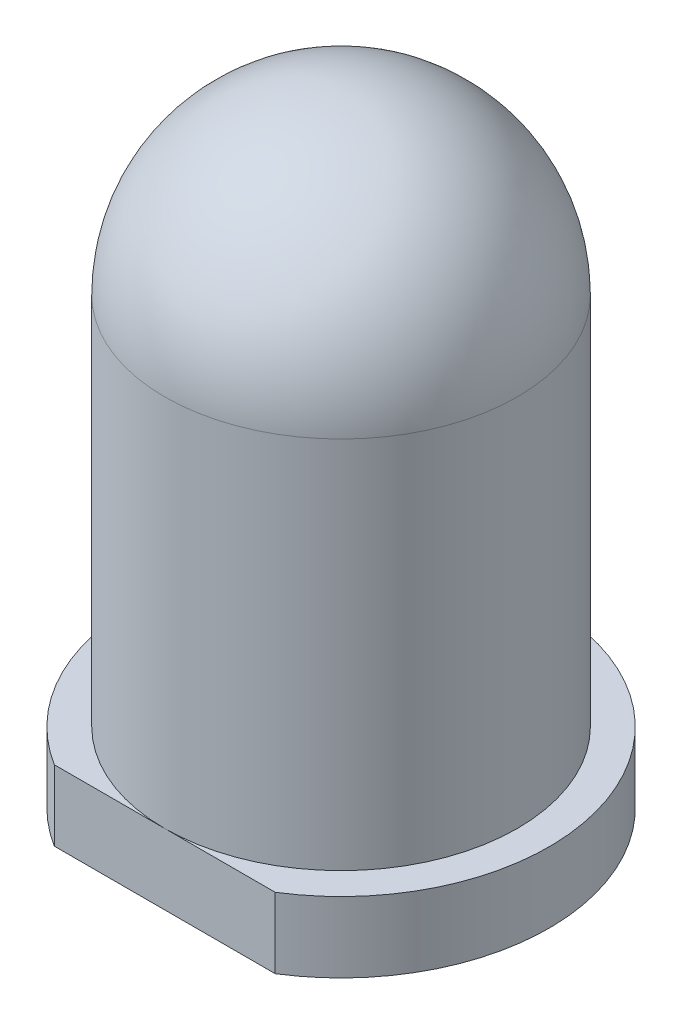
from build123d import *

# Parameters (mm, degrees)
SKETCH1_R               = 2.95
BOSS_EXTRUDE4_DEPTH     = 1
SKETCH2_R               = 2.5
BOSS_EXTRUDE5_DEPTH     = 7.8
SKETCH4_W               = 16.58699552
SKETCH4_H               = 3.788232685
CUT_EXTRUDE2_DEPTH      = 8.8
CUT_EXTRUDE2_DEPTH_BACK = 2


with BuildPart() as part:
    # Sketch1 → Boss-Extrude4 (new body)
    with BuildSketch(Plane(origin=(0, 0, 0), x_dir=(1, 0, 0), z_dir=(0, 1, 0))):
        Circle(SKETCH1_R)
    extrude(amount=BOSS_EXTRUDE4_DEPTH)

    # Sketch2 → Boss-Extrude5 (add)
    with BuildSketch(Plane(origin=(0, 1, 0), x_dir=(1, 0, 0), z_dir=(0, 1, 0))):
        Circle(SKETCH2_R)
    extrude(amount=BOSS_EXTRUDE5_DEPTH)

    # Sketch3 → Cut-Revolve5 (revolve, cut)
    with BuildSketch(Plane(origin=(0, 0, 0), x_dir=(0, 0, -1), z_dir=(1, 0, 0))):
        with BuildLine():
            ThreePointArc((0, 8.8), (-1.767766953, 8.067766953), (-2.5, 6.3))
            Line((-2.5, 6.3), (-2.5, 1))
            Line((-2.5, 1), (-5.449902287, 1))
            Line((-5.449902287, 1), (-5.449902287, 10.727798838))
            Line((-5.449902287, 10.727798838), (0, 10.727798838))
            Line((0, 10.727798838), (0, 8.8))
        make_face()
    revolve(axis=Axis((0, 11.133122405, 0), (0, -1, 0)), mode=Mode.SUBTRACT)

    # Sketch4 → Cut-Extrude2 (cut, two sides)
    with BuildSketch(Plane(origin=(0, 1, 0), x_dir=(1, 0, 0), z_dir=(0, 1, 0))) as cut_extrude2_sk:
        with Locations((1.563846093, -4.394116343)):
            Rectangle(SKETCH4_W, SKETCH4_H)
    extrude(amount=CUT_EXTRUDE2_DEPTH, mode=Mode.SUBTRACT)
    extrude(cut_extrude2_sk.sketch, amount=-CUT_EXTRUDE2_DEPTH_BACK, mode=Mode.SUBTRACT)


solid = part.part
